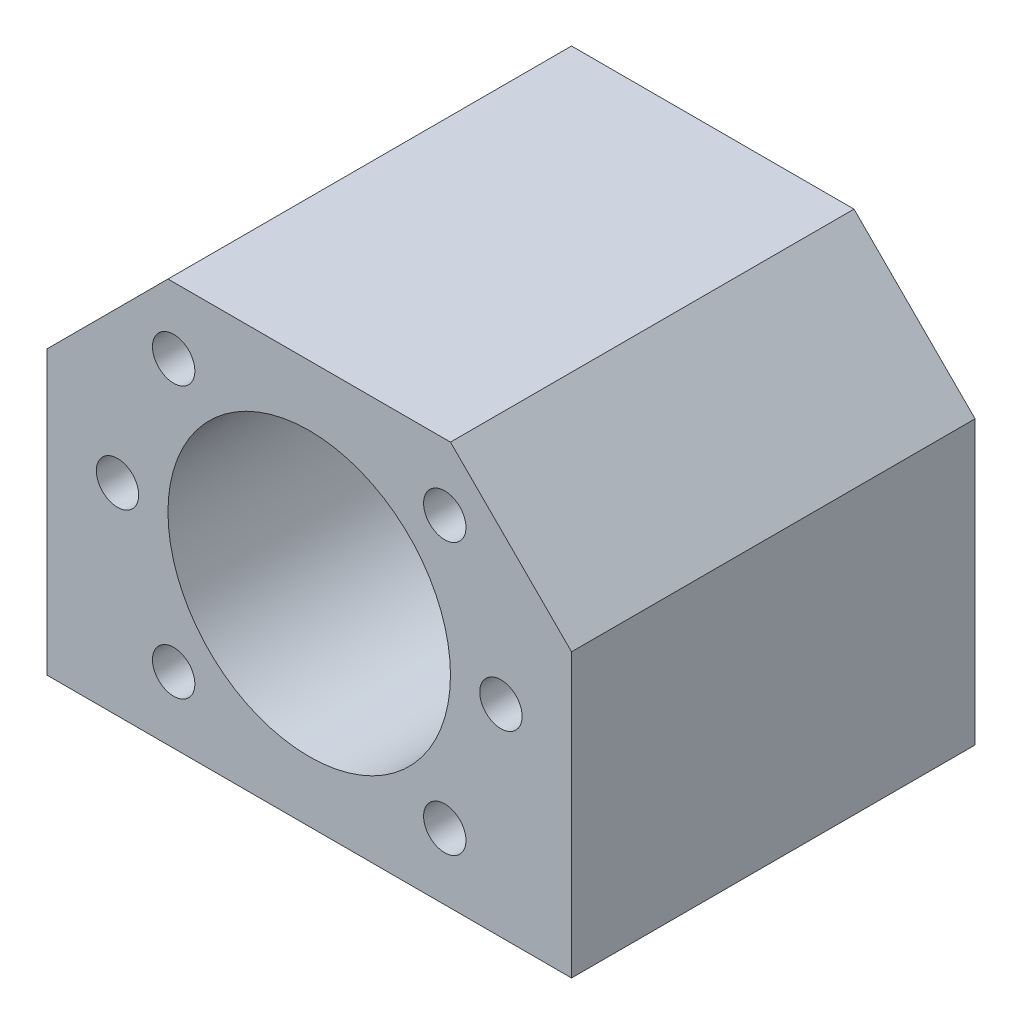
from build123d import *

# Parameters (mm, degrees)
SALIENTE_EXTRUIR2_DEPTH   = 40
CROQUIS4_R                = 14
CORTAR_EXTRUIR2_DEPTH     = 41
TALADRO_ROSCADO_M51_D     = 4.2
TALADRO_ROSCADO_M51_DEPTH = 15
TALADRO_ROSCADO_M51_TIP   = 1.2618073
TALADRO_ROSCADO_M52_D     = 4.2
TALADRO_ROSCADO_M52_DEPTH = 15
TALADRO_ROSCADO_M52_TIP   = 1.2618073
TALADRO_ROSCADO_M53_D     = 4.2
TALADRO_ROSCADO_M53_DEPTH = 15
TALADRO_ROSCADO_M53_TIP   = 1.2618073
CROQUIS20_R               = 2.1
CORTAR_EXTRUIR3_DEPTH     = 15


with BuildPart() as part:
    # Croquis3 → Saliente-Extruir2 (new body)
    with BuildSketch(Plane.XY):
        Polygon((-26, 8), (-14, 20), (14, 20), (26, 8), (26, -20), (-26, -20), align=None)
    extrude(amount=SALIENTE_EXTRUIR2_DEPTH)

    # Croquis4 → Cortar-Extruir2 (cut, through all)
    with BuildSketch(Plane.XY.offset(40)):
        Circle(CROQUIS4_R)
    extrude(amount=-CORTAR_EXTRUIR2_DEPTH, mode=Mode.SUBTRACT)

    # Taladro roscado M51
    with Locations(Plane.XY.offset(40)):
        with Locations((-13.435028843, 13.435028843)):
            Hole(TALADRO_ROSCADO_M51_D / 2, depth=TALADRO_ROSCADO_M51_DEPTH)
            with Locations((0, 0, -(TALADRO_ROSCADO_M51_DEPTH + TALADRO_ROSCADO_M51_TIP / 2))):  # 118° drill point
                Cone(0, TALADRO_ROSCADO_M51_D / 2, TALADRO_ROSCADO_M51_TIP, mode=Mode.SUBTRACT)

    # Taladro roscado M52
    with Locations(Plane.XY.offset(40)):
        with Locations((-19, 0)):
            Hole(TALADRO_ROSCADO_M52_D / 2, depth=TALADRO_ROSCADO_M52_DEPTH)
            with Locations((0, 0, -(TALADRO_ROSCADO_M52_DEPTH + TALADRO_ROSCADO_M52_TIP / 2))):  # 118° drill point
                Cone(0, TALADRO_ROSCADO_M52_D / 2, TALADRO_ROSCADO_M52_TIP, mode=Mode.SUBTRACT)

    # Taladro roscado M53
    with Locations(Plane.XY.offset(40)):
        with Locations((-13.435028843, -13.435028843), (13.435028843, -13.435028843), (19, 0), (13.435028843, 13.435028843)):
            Hole(TALADRO_ROSCADO_M53_D / 2, depth=TALADRO_ROSCADO_M53_DEPTH)
            with Locations((0, 0, -(TALADRO_ROSCADO_M53_DEPTH + TALADRO_ROSCADO_M53_TIP / 2))):  # 118° drill point
                Cone(0, TALADRO_ROSCADO_M53_D / 2, TALADRO_ROSCADO_M53_TIP, mode=Mode.SUBTRACT)

    # Croquis20 → Cortar-Extruir3 (cut)
    with BuildSketch(Plane(origin=(0, -20, 0), x_dir=(1, 0, 0), z_dir=(0, 1, 0))):
        with Locations((-20, -32)):
            Circle(CROQUIS20_R)
        with Locations((20, -32)):
            Circle(CROQUIS20_R)
        with Locations((-20, -8)):
            Circle(CROQUIS20_R)
        with Locations((20, -8)):
            Circle(CROQUIS20_R)
    extrude(amount=CORTAR_EXTRUIR3_DEPTH, mode=Mode.SUBTRACT)


solid = part.part
